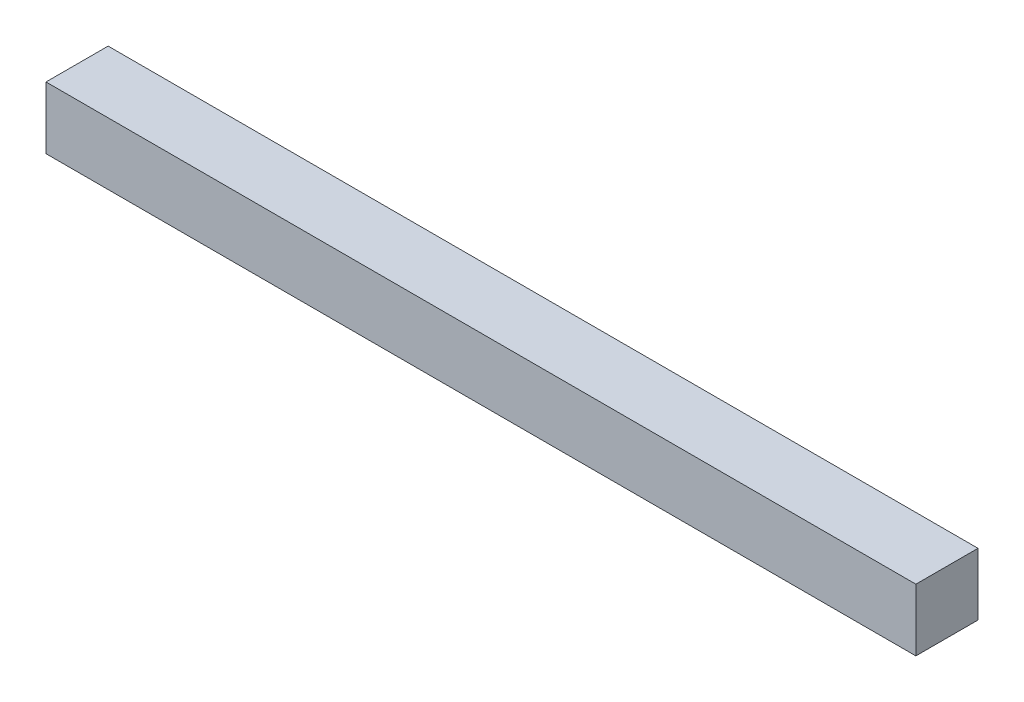
from build123d import *

# Parameters (mm, degrees)
SKETCH1_W           = 3.175
SKETCH1_H           = 3.175
BOSS_EXTRUDE1_DEPTH = 44.45


with BuildPart() as part:
    # Sketch1 → Boss-Extrude1 (new body)
    with BuildSketch(Plane(origin=(0, 0, 0), x_dir=(0, 0, -1), z_dir=(1, 0, 0))):
        Rectangle(SKETCH1_W, SKETCH1_H)
    extrude(amount=BOSS_EXTRUDE1_DEPTH)


solid = part.part
